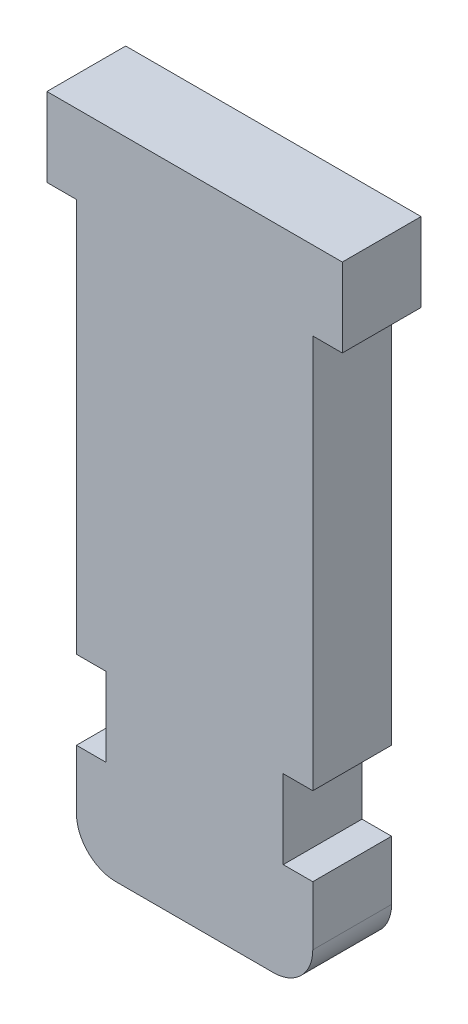
from build123d import *

# Parameters (mm, degrees)
SKIZZE1_W                       = 12
SKIZZE1_H                       = 29
SKIZZE1_W_2                     = 15
SKIZZE1_H_2                     = 4
AUFSATZ_LINEAR_AUSTRAGEN1_DEPTH = 4
SKIZZE2_W                       = 1.5
SKIZZE2_H                       = 4
SCHNITT_LINEAR_AUSTRAGEN1_DEPTH = 5
VERRUNDUNG1_R                   = 2


with BuildPart() as part:
    # Skizze1 → Aufsatz-Linear austragen1 (new body)
    with BuildSketch(Plane.XY):
        with Locations((0, -16.5)):
            Rectangle(SKIZZE1_W, SKIZZE1_H)
        Rectangle(SKIZZE1_W_2, SKIZZE1_H_2)
    extrude(amount=AUFSATZ_LINEAR_AUSTRAGEN1_DEPTH)

    # Skizze2 → Schnitt-Linear austragen1 (cut, through all)
    with BuildSketch(Plane.XY.offset(4)):
        with Locations((-5.25, -24)):
            Rectangle(SKIZZE2_W, SKIZZE2_H)
        with Locations((5.25, -24)):
            Rectangle(SKIZZE2_W, SKIZZE2_H)
    extrude(amount=-SCHNITT_LINEAR_AUSTRAGEN1_DEPTH, mode=Mode.SUBTRACT)

    # Verrundung1
    verrundung1_edges = [part.edges().sort_by_distance(p)[0] for p in [
        (6, -31, 2),
        (-6, -31, 2),
    ]]
    fillet(verrundung1_edges, radius=VERRUNDUNG1_R)


solid = part.part
